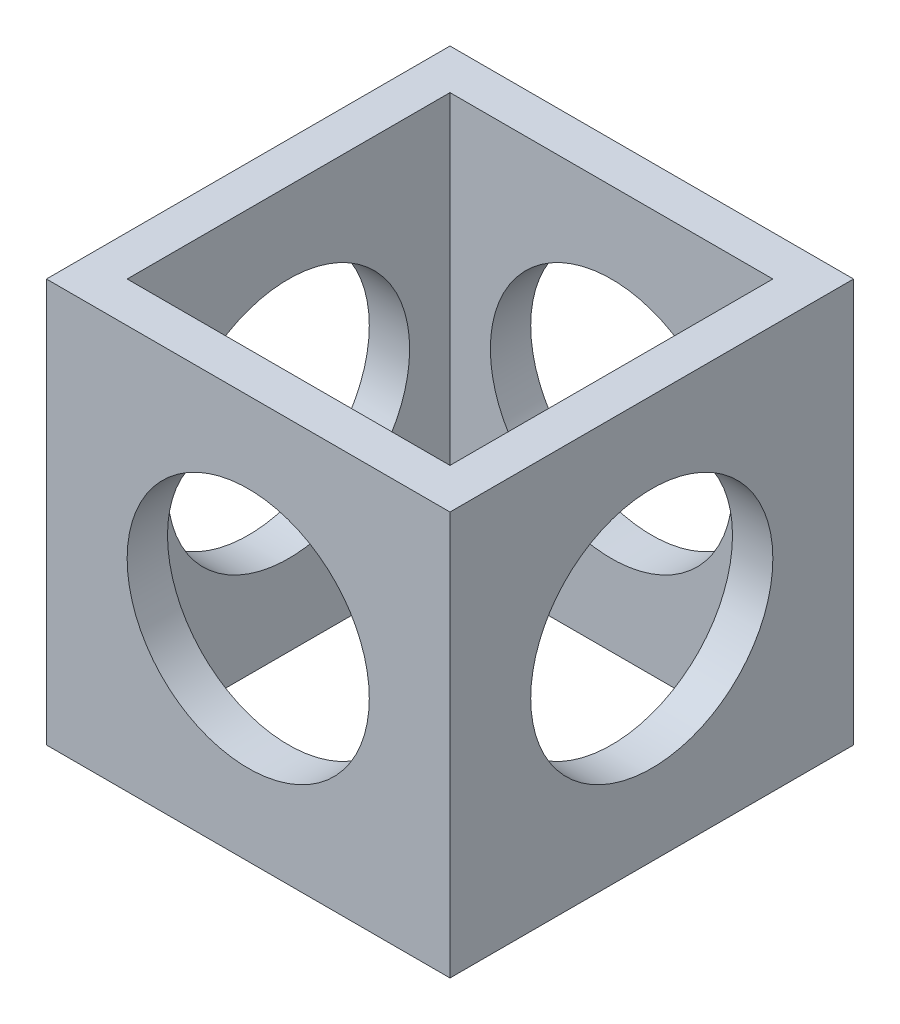
from build123d import *

# Parameters (mm, degrees)
CROQUIS1_W              = 50
CROQUIS1_H              = 50
CROQUIS1_W_2            = 40
CROQUIS1_H_2            = 40
SALIENTE_EXTRUIR1_DEPTH = 50
CROQUIS2_R              = 15
CORTAR_EXTRUIR1_DEPTH   = 50
CROQUIS3_R              = 15
CORTAR_EXTRUIR2_DEPTH   = 50


with BuildPart() as part:
    # Croquis1 → Saliente-Extruir1 (new body)
    with BuildSketch(Plane(origin=(0, 0, 0), x_dir=(1, 0, 0), z_dir=(0, 1, 0))):
        Rectangle(CROQUIS1_W, CROQUIS1_H)
        Rectangle(CROQUIS1_W_2, CROQUIS1_H_2, mode=Mode.SUBTRACT)
    extrude(amount=SALIENTE_EXTRUIR1_DEPTH)

    # Croquis2 → Cortar-Extruir1 (cut)
    with BuildSketch(Plane(origin=(25, 0, 0), x_dir=(0, 0, -1), z_dir=(1, 0, 0))):
        with Locations((0, 25)):
            Circle(CROQUIS2_R)
    extrude(amount=-CORTAR_EXTRUIR1_DEPTH, mode=Mode.SUBTRACT)

    # Croquis3 → Cortar-Extruir2 (cut)
    with BuildSketch(Plane(origin=(0, 0, -25), x_dir=(-1, 0, 0), z_dir=(0, 0, -1))):
        with Locations((0, 25)):
            Circle(CROQUIS3_R)
    extrude(amount=-CORTAR_EXTRUIR2_DEPTH, mode=Mode.SUBTRACT)


solid = part.part
